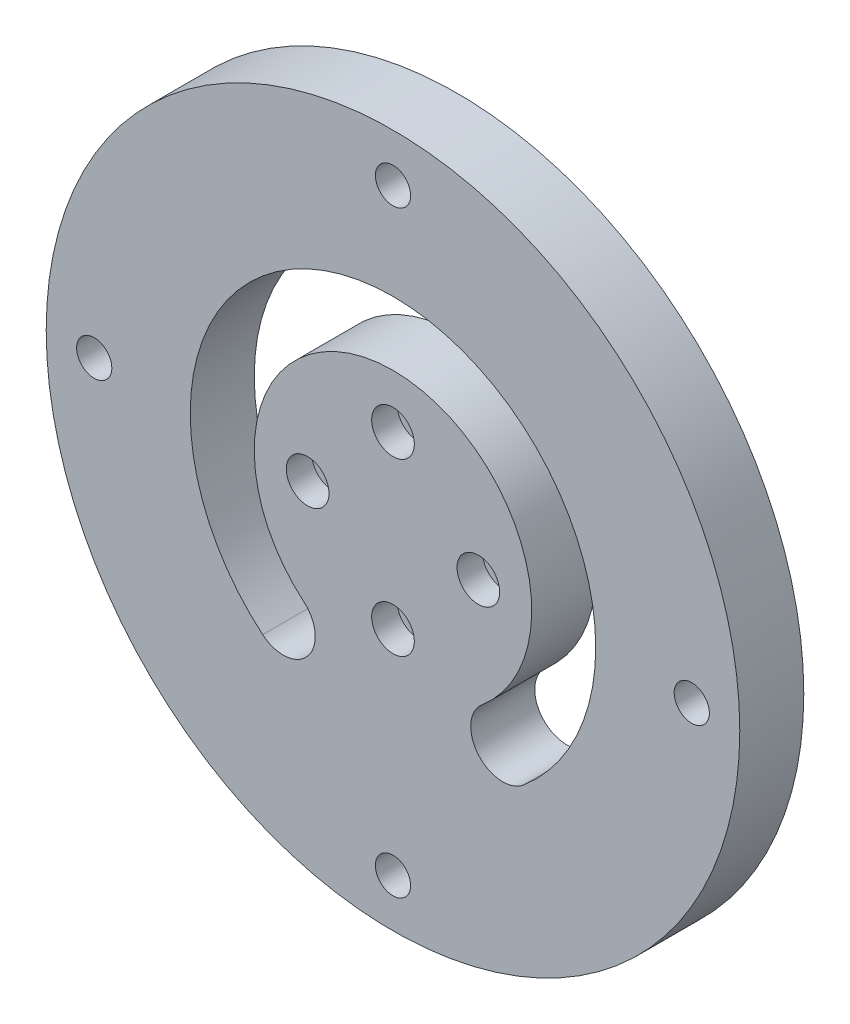
from build123d import *

# Parameters (mm, degrees)
SKETCH1_R           = 32.5
BOSS_EXTRUDE1_DEPTH = 6
SKETCH16_R          = 1.1
CUT_EXTRUDE8_DEPTH  = 47.351914739
SKETCH17_R          = 2
CUT_EXTRUDE9_DEPTH  = 2.4
SKETCH12_R          = 1.65
CUT_EXTRUDE10_DEPTH = 47.351914739
CUT_EXTRUDE11_DEPTH = 3
CUT_EXTRUDE12_DEPTH = 47.351914739


with BuildPart() as part:
    # Sketch1 → Boss-Extrude1 (new body)
    with BuildSketch(Plane.XY):
        Circle(SKETCH1_R)
    extrude(amount=BOSS_EXTRUDE1_DEPTH)

    # Sketch16 → Cut-Extrude8 (cut, through all)
    with BuildSketch(Plane.XY.offset(6)):
        with Locations((8, 0)):
            Circle(SKETCH16_R)
        with Locations((-8, 0)):
            Circle(SKETCH16_R)
        with Locations((0, -8)):
            Circle(SKETCH16_R)
        with Locations((0, 8)):
            Circle(SKETCH16_R)
    extrude(amount=-CUT_EXTRUDE8_DEPTH, mode=Mode.SUBTRACT)

    # Sketch17 → Cut-Extrude9 (cut)
    with BuildSketch(Plane.XY.offset(6)):
        with Locations((8, 0)):
            Circle(SKETCH17_R)
        with Locations((-8, 0)):
            Circle(SKETCH17_R)
        with Locations((0, -8)):
            Circle(SKETCH17_R)
        with Locations((0, 8)):
            Circle(SKETCH17_R)
    extrude(amount=-CUT_EXTRUDE9_DEPTH, mode=Mode.SUBTRACT)

    # Sketch12 → Cut-Extrude10 (cut, through all)
    with BuildSketch(Plane.XY.offset(6)):
        with Locations((0, 28)):
            Circle(SKETCH12_R)
        with Locations((28, 0)):
            Circle(SKETCH12_R)
        with Locations((0, -28)):
            Circle(SKETCH12_R)
        with Locations((-28, 0)):
            Circle(SKETCH12_R)
    extrude(amount=-CUT_EXTRUDE10_DEPTH, mode=Mode.SUBTRACT)

    # Sketch18 → Cut-Extrude11 (cut)
    with BuildSketch(Plane(origin=(0, 0, 0), x_dir=(-1, 0, 0), z_dir=(0, 0, -1))):
        Polygon((1.616580754, 30.8), (-1.616580754, 30.8), (-3.233161507, 28), (-1.616580754, 25.2), (1.616580754, 25.2), (3.233161507, 28), align=None)
        Polygon((29.616580754, 2.8), (26.383419246, 2.8), (24.766838493, 0), (26.383419246, -2.8), (29.616580754, -2.8), (31.233161507, 0), align=None)
        Polygon((1.616580754, -25.2), (-1.616580754, -25.2), (-3.233161507, -28), (-1.616580754, -30.8), (1.616580754, -30.8), (3.233161507, -28), align=None)
        Polygon((-26.383419246, 2.8), (-29.616580754, 2.8), (-31.233161507, 0), (-29.616580754, -2.8), (-26.383419246, -2.8), (-24.766838493, 0), align=None)
    extrude(amount=-CUT_EXTRUDE11_DEPTH, mode=Mode.SUBTRACT)

    # Sketch19 → Cut-Extrude12 (cut, through all)
    with BuildSketch(Plane.XY.offset(6)):
        with BuildLine():
            ThreePointArc((12.212964584, -14.554844419), (0, 19), (-12.212964584, -14.554844419))
            ThreePointArc((-12.212964584, -14.554844419), (-7.986468426, -14.185073919), (-8.356238926, -9.958577761))
            ThreePointArc((-8.356238926, -9.958577761), (0, 13), (8.356238926, -9.958577761))
            ThreePointArc((8.356238926, -9.958577761), (7.986468426, -14.185073919), (12.212964584, -14.554844419))
        make_face()
    extrude(amount=-CUT_EXTRUDE12_DEPTH, mode=Mode.SUBTRACT)


solid = part.part
